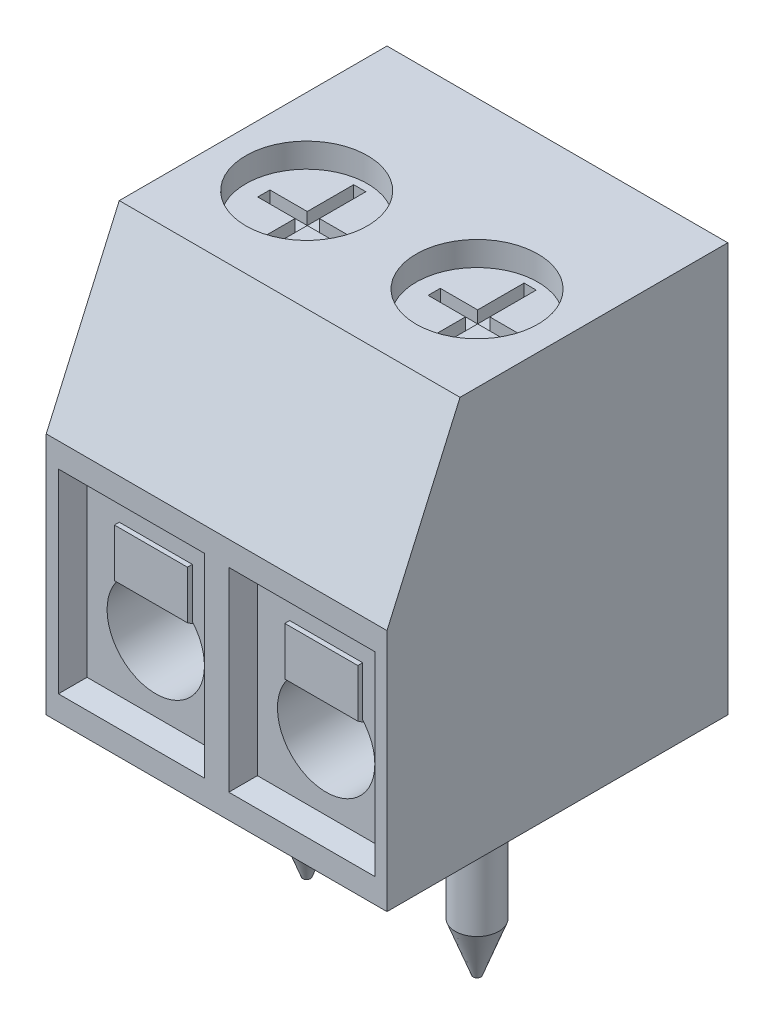
from build123d import *

# Parameters (mm, degrees)
BOSS_EXTRUDE1_DEPTH         = 7
SKETCH2_R                   = 1.25
CUT_EXTRUDE1_DEPTH          = 0.5
SKETCH3_W                   = 3
SKETCH3_H                   = 4
CUT_EXTRUDE2_DEPTH          = 0.5
CUT_EXTRUDE2_TAPER          = 10
SKETCH4_R                   = 1
CUT_EXTRUDE3_DEPTH          = 6
SKETCH6_R                   = 0.45
BOSS_EXTRUDE3_DEPTH         = 3.8
CHAMFER1_SIZE               = 1
CHAMFER1_SIZE2              = 0.371896666
EXTRUDE_THIN1_DEPTH         = 0.75
SKETCH8_W                   = 0.25
SKETCH8_H                   = 2.158330758
SKETCH8_W_2                 = 1.874325027
SKETCH8_H_2                 = 0.25
CUT_EXTRUDE_THIN1_DEPTH     = 0.25
LPATTERN1_COUNT             = 2
LPATTERN1_PITCH             = 3.5
CHAMFER1_OF_LPATTERN1_SIZE2 = 0.371896666
CHAMFER1_OF_LPATTERN1_SIZE  = 1


with BuildPart() as part:
    # Sketch1 → Boss-Extrude1 (new body)
    with BuildSketch(Plane(origin=(0, 0, 0), x_dir=(0, 0, -1), z_dir=(1, 0, 0))):
        Polygon((0, 5), (1.5, 8.4), (7, 8.4), (7, 0), (0, 0), align=None)
    extrude(amount=BOSS_EXTRUDE1_DEPTH)

    # Sketch2 → Cut-Extrude1 (cut)
    with BuildSketch(Plane(origin=(0, 8.4, 0), x_dir=(1, 0, 0), z_dir=(0, 1, 0))):
        with Locations((1.75, 3.6)):
            Circle(SKETCH2_R)
    cut_extrude1 = extrude(amount=-CUT_EXTRUDE1_DEPTH, mode=Mode.SUBTRACT)

    # Sketch3 → Cut-Extrude2 (cut)
    with BuildSketch(Plane.XY):
        with Locations((1.75, 2.5)):
            Rectangle(SKETCH3_W, SKETCH3_H)
    cut_extrude2 = extrude(amount=-CUT_EXTRUDE2_DEPTH, taper=CUT_EXTRUDE2_TAPER, mode=Mode.SUBTRACT)

    # Sketch4 → Cut-Extrude3 (cut)
    with BuildSketch(Plane.XY.offset(-0.5)):
        with Locations((1.75, 2)):
            Circle(SKETCH4_R)
    cut_extrude3 = extrude(amount=-CUT_EXTRUDE3_DEPTH, mode=Mode.SUBTRACT)

    # Sketch6 → Boss-Extrude3 (add)
    with BuildSketch(Plane.XZ):
        with Locations((1.75, -3.6)):
            Circle(SKETCH6_R)
    boss_extrude3 = extrude(amount=BOSS_EXTRUDE3_DEPTH)

    # Chamfer1
    chamfer1_edges = [part.edges().sort_by_distance(p)[0] for p in [
        (1.3, -3.8, -3.6),
    ]]
    chamfer1_side = [part.faces().sort_by_distance(p)[0] for p in [
        (1.3, -1.9, -3.6),
    ]]
    chamfer(chamfer1_edges, length=CHAMFER1_SIZE, length2=CHAMFER1_SIZE2, reference=chamfer1_side[0])

    # Sketch7 → Extrude-Thin1 (add, symmetric)
    with BuildSketch(Plane(origin=(1.75, 0, 0), x_dir=(0, 0, -1), z_dir=(1, 0, 0))):
        Polygon((0.5, 3.678716588), (0.5, 2.743158903), (1.89970396, 1.832221158), (5.88813409, 1.438302133), (5.878305368, 1.338786324), (1.865601336, 1.735102771), (0.4, 2.688927019), (0.4, 3.678716588), align=None)
    extrude_thin1 = extrude(amount=EXTRUDE_THIN1_DEPTH, both=True)

    # Sketch8 → Cut-Extrude-Thin1 (cut, symmetric)
    with BuildSketch(Plane(origin=(0, 7.9, 0), x_dir=(1, 0, 0), z_dir=(0, 1, 0))):
        with Locations((1.75, 3.611637798)):
            Rectangle(SKETCH8_W, SKETCH8_H)
        with Locations((1.795143175, 3.611637798)):
            Rectangle(SKETCH8_W_2, SKETCH8_H_2)
    cut_extrude_thin1 = extrude(amount=CUT_EXTRUDE_THIN1_DEPTH, both=True, mode=Mode.SUBTRACT)

    # LPattern1: Cut-Extrude1, Cut-Extrude2, Cut-Extrude3, Boss-Extrude3, Extrude-Thin1, Cut-Extrude-Thin1 ×2
    with Locations(*[(i * LPATTERN1_PITCH, 0, 0) for i in range(1, LPATTERN1_COUNT)]):
        add(cut_extrude1, mode=Mode.SUBTRACT)
        add(cut_extrude2, mode=Mode.SUBTRACT)
        add(cut_extrude3, mode=Mode.SUBTRACT)
        add(boss_extrude3)
        add(extrude_thin1)
        add(cut_extrude_thin1, mode=Mode.SUBTRACT)

    # Chamfer1 of LPattern1
    chamfer1_of_lpattern1_edges = [part.edges().sort_by_distance(p)[0] for p in [
        (4.8, -3.8, -3.6),
    ]]
    chamfer(chamfer1_of_lpattern1_edges, length=CHAMFER1_OF_LPATTERN1_SIZE, length2=CHAMFER1_OF_LPATTERN1_SIZE2)


solid = part.part
